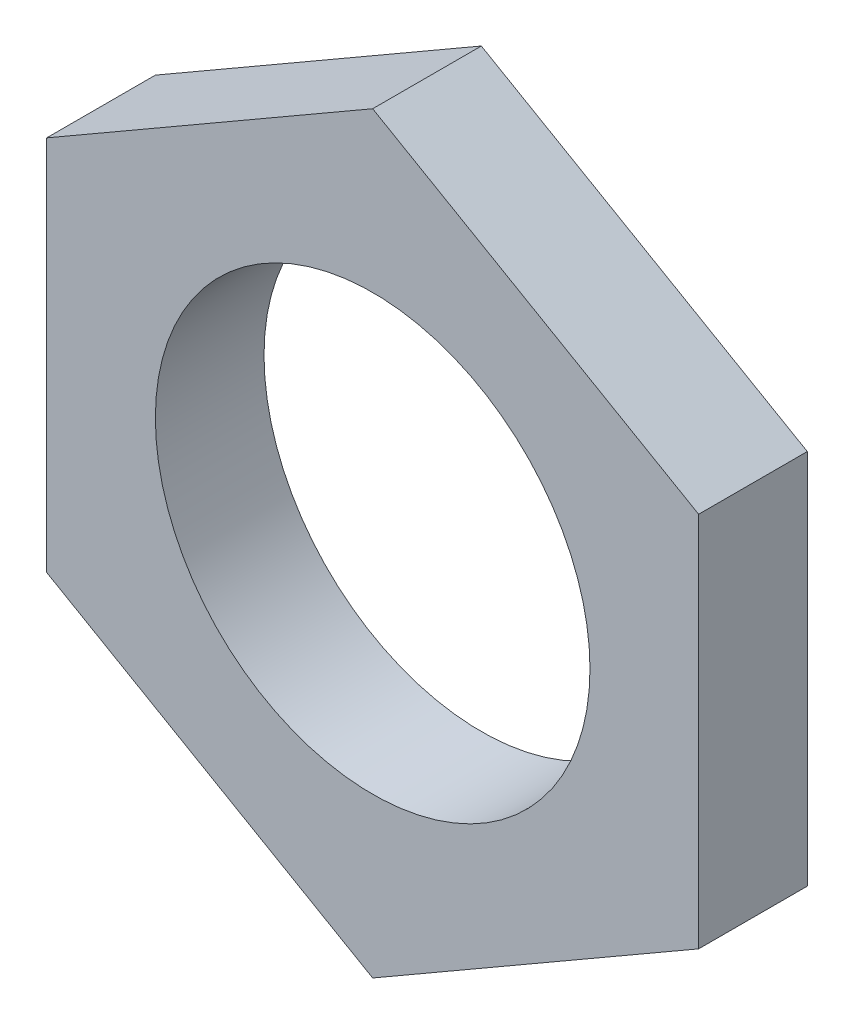
from build123d import *

# Parameters (mm, degrees)
SKETCH_1_R      = 4
EXTRUDE_1_DEPTH = 2


with BuildPart() as part:
    # Эскиз1 → Бобышка-Вытянуть1 (new body)
    with BuildSketch(Plane.XY):
        Polygon((0, 6.92820323), (-6, 3.464101615), (-6, -3.464101615), (0, -6.92820323), (6, -3.464101615), (6, 3.464101615), align=None)
        Circle(SKETCH_1_R, mode=Mode.SUBTRACT)
    extrude(amount=EXTRUDE_1_DEPTH)


solid = part.part
